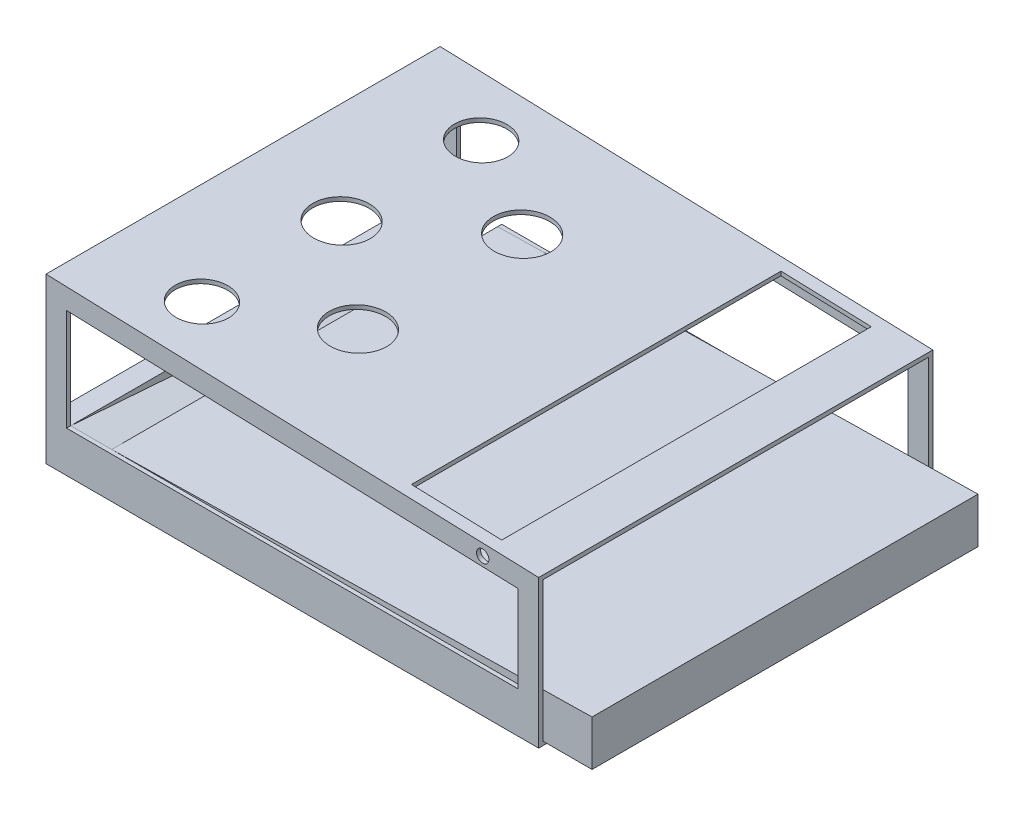
from build123d import *

# Parameters (mm, degrees)
BOSS_EXTRUDE1_DEPTH = 609.6
SHELL1_T            = -6.35
CUT_EXTRUDE1_DEPTH  = 609.6
BOSS_EXTRUDE3_DEPTH = 596.9
BOSS_EXTRUDE4_DEPTH = 95.25
SKETCH8_W           = 31.75
SKETCH8_H           = 44.45
BOSS_EXTRUDE5_DEPTH = 603.25
SKETCH9_W           = 63.5
SKETCH9_H           = 44.45
CUT_EXTRUDE2_DEPTH  = 6.35
SKETCH10_R          = 41.275
SKETCH10_R_2        = 44.45
CUT_EXTRUDE3_DEPTH  = 6.35
SKETCH12_W          = 139.7
SKETCH12_H          = 571.5
CUT_EXTRUDE4_DEPTH  = 6.35
SKETCH13_R          = 9.525
CUT_EXTRUDE5_DEPTH  = 609.6


with BuildPart() as part:
    # Sketch1 → Boss-Extrude1 (new body)
    with BuildSketch(Plane.XY):
        Polygon((-373.981578947, 0), (388.018421053, 0), (388.018421053, 228.6), (-373.981578947, 254), align=None)
    extrude(amount=-BOSS_EXTRUDE1_DEPTH)

    # Shell1
    shell1_openings = [part.faces().sort_by_distance(p)[0] for p in [
        (-373.981578947, 127, -304.8),
        (388.018421053, 114.3, -304.8),
    ]]
    offset(amount=SHELL1_T, openings=shell1_openings, kind=Kind.INTERSECTION)

    # Sketch2 → Cut-Extrude1 (cut)
    with BuildSketch(Plane.XY):
        Polygon((-342.231578947, 221.174032675), (356.268421053, 197.890699341), (356.268421053, 63.5), (-342.231578947, 63.5), align=None)
    extrude(amount=-CUT_EXTRUDE1_DEPTH, mode=Mode.SUBTRACT)

    # Sketch5 → Boss-Extrude3 (add)
    with BuildSketch(Plane.XY.offset(-603.25)):
        Polygon((-278.731578947, 63.5), (464.218421053, 76.696522884), (464.218421053, 6.35), (-278.731578947, 6.35), align=None)
    extrude(amount=BOSS_EXTRUDE3_DEPTH)

    # Sketch6 → Boss-Extrude4 (add)
    with BuildSketch(Plane.ZY.offset(278.731578947)):
        Polygon((-6.35, 63.5), (-603.25, 19.05), (-603.25, 6.35), (-6.35, 6.35), align=None)
    extrude(amount=BOSS_EXTRUDE4_DEPTH)

    # Sketch8 → Boss-Extrude5 (add)
    with BuildSketch(Plane(origin=(0, 0, -609.6), x_dir=(-1, 0, 0), z_dir=(0, 0, -1))):
        with Locations((358.106578947, 41.275)):
            Rectangle(SKETCH8_W, SKETCH8_H)
    extrude(amount=-BOSS_EXTRUDE5_DEPTH)

    # Sketch9 → Cut-Extrude2 (cut)
    with BuildSketch(Plane(origin=(0, 0, -609.6), x_dir=(-1, 0, 0), z_dir=(0, 0, -1))):
        with Locations((310.481578947, 41.275)):
            Rectangle(SKETCH9_W, SKETCH9_H)
    extrude(amount=-CUT_EXTRUDE2_DEPTH, mode=Mode.SUBTRACT)

    # Sketch10 → Cut-Extrude3 (cut)
    with BuildSketch(Plane(origin=(8.042195806, 241.265874175, 0), x_dir=(0.999444907, -0.03331483, 0), z_dir=(0.03331483, 0.999444907, 0))):
        with Locations((-229.835951262, 88.9)):
            Circle(SKETCH10_R)
        with Locations((-229.835951262, 520.7)):
            Circle(SKETCH10_R)
        with Locations((-77.435951262, 431.8)):
            Circle(SKETCH10_R_2)
        with Locations((-77.435951262, 177.8)):
            Circle(SKETCH10_R_2)
        with Locations((-229.835951262, 304.8)):
            Circle(SKETCH10_R_2)
    extrude(amount=-CUT_EXTRUDE3_DEPTH, mode=Mode.SUBTRACT)

    # Sketch12 → Cut-Extrude4 (cut)
    with BuildSketch(Plane(origin=(8.042195806, 241.265874175, 0), x_dir=(0.999444907, -0.03331483, 0), z_dir=(0.03331483, 0.999444907, 0))):
        with Locations((234.137264544, 304.8)):
            Rectangle(SKETCH12_W, SKETCH12_H)
    extrude(amount=-CUT_EXTRUDE4_DEPTH, mode=Mode.SUBTRACT)

    # Sketch13 → Cut-Extrude5 (cut)
    with BuildSketch(Plane.XY):
        with Locations((301.467767378, 213.990365252)):
            Circle(SKETCH13_R)
    extrude(amount=-CUT_EXTRUDE5_DEPTH, mode=Mode.SUBTRACT)


solid = part.part
